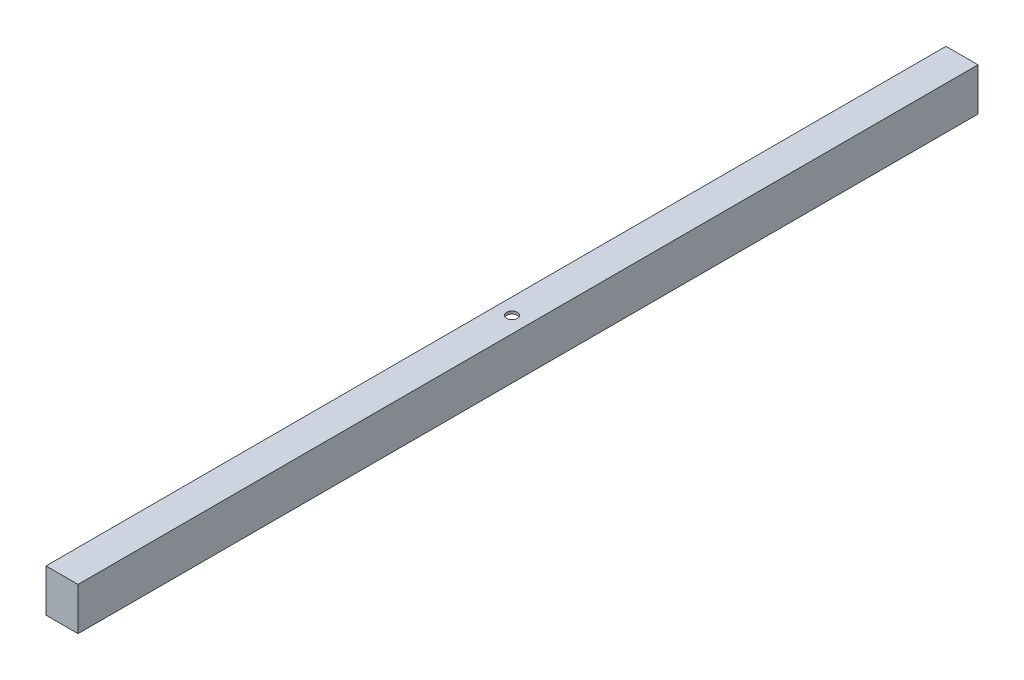
from build123d import *

# Parameters (mm, degrees)
BOSS_EXTRUDE1_DEPTH = 533.4
SKETCH2_R           = 3.175
CUT_EXTRUDE1_DEPTH  = 381
SKETCH4_W           = 19.05
SKETCH4_H           = 25.4
BOSS_EXTRUDE3_DEPTH = 1.016
SKETCH5_W           = 19.05
SKETCH5_H           = 25.4
BOSS_EXTRUDE4_DEPTH = 1.016


with BuildPart() as part:
    # Sketch1 → Boss-Extrude1 (new body)
    with BuildSketch(Plane.XY):
        Polygon((0, 0), (17.4625, 0), (17.4625, -22.225), (0, -22.225), (0, -23.8125), (12.7, -23.8125), (19.05, -23.8125), (19.05, 0), (19.05, 1.5875), (0, 1.5875), align=None)
    extrude(amount=BOSS_EXTRUDE1_DEPTH)

    # Sketch2 → Cut-Extrude1 (cut)
    with BuildSketch(Plane(origin=(0, 1.5875, 0), x_dir=(1, 0, 0), z_dir=(0, 1, 0))):
        with Locations((9.525, -266.7)):
            Circle(SKETCH2_R)
    extrude(amount=-CUT_EXTRUDE1_DEPTH, mode=Mode.SUBTRACT)

    # Sketch4 → Boss-Extrude3 (add)
    with BuildSketch(Plane(origin=(0, 0, 0), x_dir=(-1, 0, 0), z_dir=(0, 0, -1))):
        with Locations((-9.525, -11.1125)):
            Rectangle(SKETCH4_W, SKETCH4_H)
    extrude(amount=BOSS_EXTRUDE3_DEPTH)

    # Sketch5 → Boss-Extrude4 (add)
    with BuildSketch(Plane.XY.offset(533.4)):
        with Locations((9.525, -11.1125)):
            Rectangle(SKETCH5_W, SKETCH5_H)
    extrude(amount=BOSS_EXTRUDE4_DEPTH)


solid = part.part
